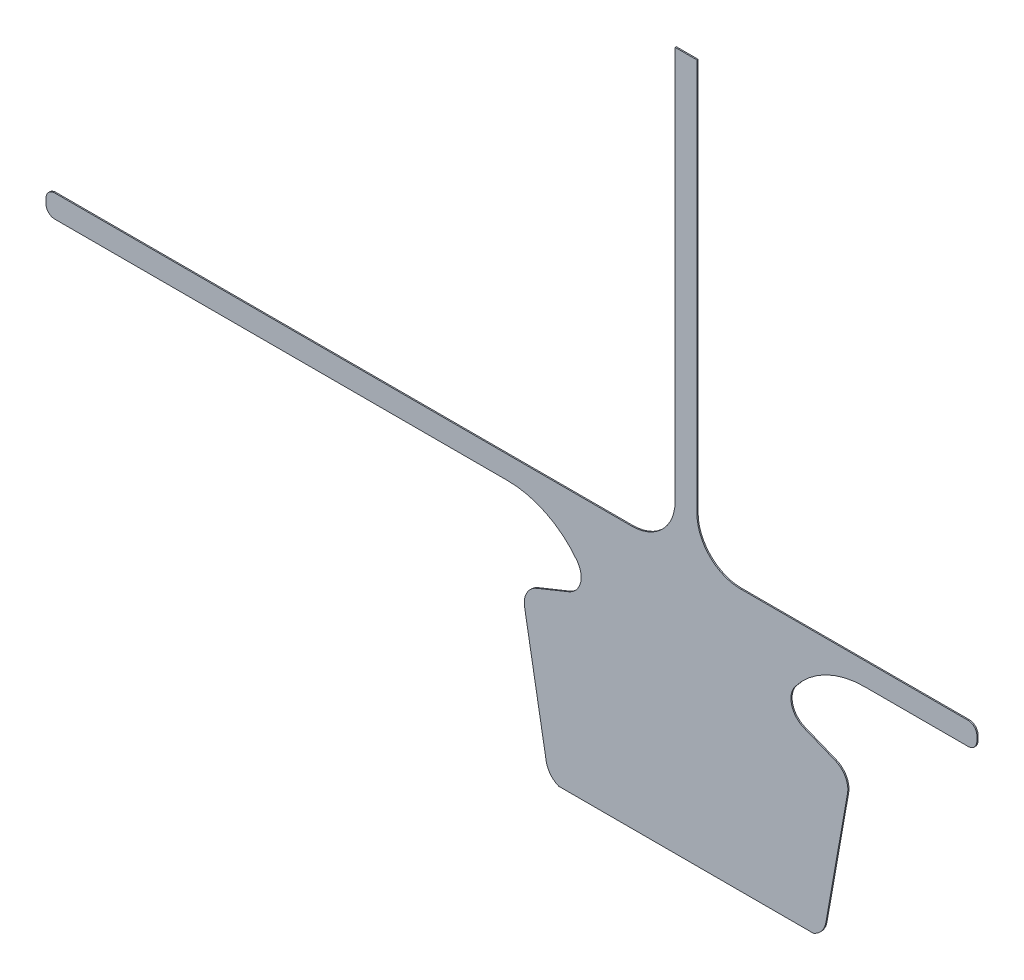
from build123d import *

# Parameters (mm, degrees)
BOSS_EXTRUDE1_DEPTH = 1.016


with BuildPart() as part:
    # Sketch1 → Boss-Extrude1 (new body)
    with BuildSketch(Plane.XY):
        with BuildLine():
            Line((-102.690520384, 151.318398839), (-130.138661403, 140.228630017))
            ThreePointArc((-130.138661403, 140.228630017), (-139.028894565, 132.36321613), (-140.988038021, 120.655836484))
            Line((-140.988038021, 120.655836484), (-122.083041186, 13.440271634))
            ThreePointArc((-122.083041186, 13.440271634), (-118.354836941, 5.294136523), (-111.127725304, 0))
            Line((-111.127725304, 0), (111.127725304, 0))
            ThreePointArc((111.127725304, 0), (118.354836941, 5.294136523), (122.083041186, 13.440271634))
            Line((122.083041186, 13.440271634), (140.988038021, 120.655836484))
            ThreePointArc((140.988038021, 120.655836484), (139.028894565, 132.36321613), (130.138661403, 140.228630017))
            Line((130.138661403, 140.228630017), (102.690520384, 151.318398839))
            ThreePointArc((102.690520384, 151.318398839), (92.216863272, 163.055161588), (95.154949405, 178.50885833))
            ThreePointArc((95.154949405, 178.50885833), (122.006673364, 200.829543277), (155.995276019, 208.829727371))
            Line((155.995276019, 208.829727371), (246.294572316, 208.829727371))
            ThreePointArc((246.294572316, 208.829727371), (251.682725989, 211.061573699), (253.914572316, 216.449727371))
            Line((253.914572316, 216.449727371), (253.914572316, 220.98))
            ThreePointArc((253.914572316, 220.98), (251.682725989, 226.368153673), (246.294572316, 228.6))
            Line((246.294572316, 228.6), (47.442005026, 228.6))
            ThreePointArc((47.442005026, 228.6), (20.63063365, 239.70563365), (9.525, 266.517005026))
            Line((9.525, 266.517005026), (9.525, 609.6))
            Line((9.525, 609.6), (-9.525, 609.6))
            Line((-9.525, 609.6), (-9.525, 266.517005026))
            ThreePointArc((-9.525, 266.517005026), (-20.63063365, 239.70563365), (-47.442005026, 228.6))
            Line((-47.442005026, 228.6), (-551.265427684, 228.6))
            ThreePointArc((-551.265427684, 228.6), (-556.653581357, 226.368153673), (-558.885427684, 220.98))
            Line((-558.885427684, 220.98), (-558.885427684, 216.449727371))
            ThreePointArc((-558.885427684, 216.449727371), (-556.653581357, 211.061573699), (-551.265427684, 208.829727371))
            Line((-551.265427684, 208.829727371), (-155.995276019, 208.829727371))
            ThreePointArc((-155.995276019, 208.829727371), (-122.006673364, 200.829543277), (-95.154949405, 178.50885833))
            ThreePointArc((-95.154949405, 178.50885833), (-92.216863272, 163.055161588), (-102.690520384, 151.318398839))
        make_face()
    extrude(amount=BOSS_EXTRUDE1_DEPTH)


solid = part.part
